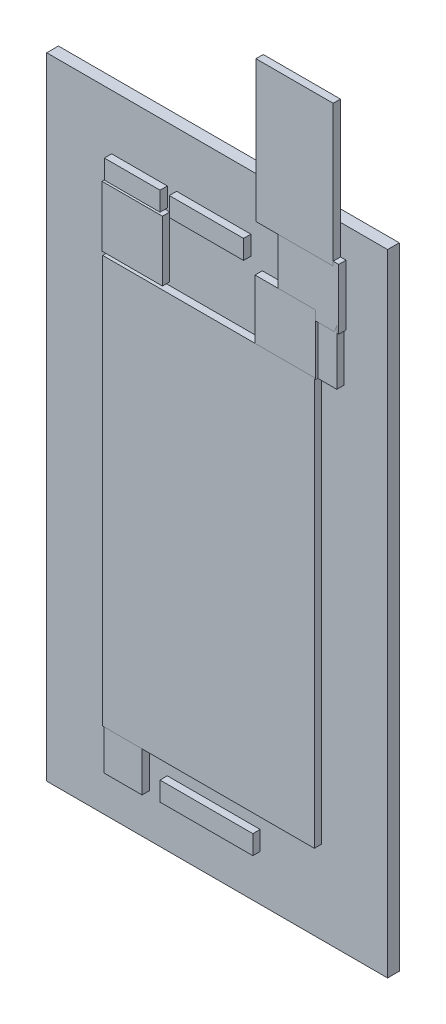
from build123d import *

# Parameters (mm, degrees)
SKETCH1_W                        = 46.66
SKETCH1_H                        = 86.35
BOARD_DEPTH                      = 1.6
SKETCH2_W                        = 8.2804
SKETCH2_H                        = 8.2804
EXTRUDE_E3_5_8_1_DEPTH           = 1
SKETCH3_W                        = 8.2804
SKETCH3_H                        = 8.2804
EXTRUDE_E3_5_8_2_DEPTH           = 1
SKETCH4_W                        = 8.2804
SKETCH4_H                        = 8.2804
EXTRUDE_E3_5_8_3_DEPTH           = 1
SKETCH5_W                        = 10.16
SKETCH5_H                        = 2.6162
DO41_10_1_DEPTH                  = 1
SKETCH6_W                        = 10.5664
SKETCH6_H                        = 19.304
TO220H_1_DEPTH                   = 1
SKETCH7_W                        = 5.2324
SKETCH7_H                        = 5.9182
DIL04_1_DEPTH                    = 1
SKETCH8_W                        = 13.0048
SKETCH8_H                        = 2.286
EXTRUDE_0207_12_1_DEPTH          = 1
SKETCH9_W                        = 13.0048
SKETCH9_H                        = 2.286
EXTRUDE_0207_12_2_DEPTH          = 1
SKETCH10_W                       = 2.6162
SKETCH10_H                       = 7.62
EXTRUDE_1X03_1_DEPTH             = 1
SKETCH11_W                       = 7.62
SKETCH11_H                       = 2.6162
EXTRUDE_1X03_2_DEPTH             = 1
SKETCH12_W                       = 12.7
SKETCH12_H                       = 2.6162
EXTRUDE_1X05_1_DEPTH             = 1
SKETCH13_W                       = 28.97
SKETCH13_H                       = 55.8
MODULE_ESP32_DEVKITC_32U_1_DEPTH = 1


with BuildPart() as part:
    # Sketch1 → BOARD (new body)
    with BuildSketch(Plane.XY):
        with Locations((13.17, 43.175)):
            Rectangle(SKETCH1_W, SKETCH1_H)
    extrude(amount=BOARD_DEPTH)


with BuildPart() as body_2:
    # Sketch2 → Extrude E3_5-8-1 (new body)
    with BuildSketch(Plane.XY.offset(1.6)):
        with Locations((2.54, 71.755)):
            Rectangle(SKETCH2_W, SKETCH2_H)
    extrude(amount=EXTRUDE_E3_5_8_1_DEPTH)


with BuildPart() as body_3:
    # Sketch3 → Extrude E3_5-8-2 (new body)
    with BuildSketch(Plane.XY.offset(1.6)):
        with Locations((26.67, 78.105)):
            Rectangle(SKETCH3_W, SKETCH3_H)
    extrude(amount=EXTRUDE_E3_5_8_2_DEPTH)


with BuildPart() as body_4:
    # Sketch4 → Extrude E3_5-8-3 (new body)
    with BuildSketch(Plane.XY.offset(1.6)):
        with Locations((23.495, 71.12)):
            Rectangle(SKETCH4_W, SKETCH4_H)
    extrude(amount=EXTRUDE_E3_5_8_3_DEPTH)


with BuildPart() as body_5:
    # Sketch5 → DO41-10-1 (new body)
    with BuildSketch(Plane.XY.offset(1.6)):
        with Locations((12.7, 77.5081)):
            Rectangle(SKETCH5_W, SKETCH5_H)
    extrude(amount=DO41_10_1_DEPTH)


with BuildPart() as body_6:
    # Sketch6 → TO220H-1 (new body)
    with BuildSketch(Plane.XY.offset(1.6)):
        with Locations((24.765, 91.313)):
            Rectangle(SKETCH6_W, SKETCH6_H)
    extrude(amount=TO220H_1_DEPTH)


with BuildPart() as body_7:
    # Sketch7 → DIL04-1 (new body)
    with BuildSketch(Plane.XY.offset(1.6)):
        with Locations((1.27, 8.8519)):
            Rectangle(SKETCH7_W, SKETCH7_H)
    extrude(amount=DIL04_1_DEPTH)


with BuildPart() as body_8:
    # Sketch8 → Extrude 0207_12-1 (new body)
    with BuildSketch(Plane.XY.offset(1.6)):
        with Locations((10.0076, 34.29)):
            Rectangle(SKETCH8_W, SKETCH8_H)
    extrude(amount=EXTRUDE_0207_12_1_DEPTH)


with BuildPart() as body_9:
    # Sketch9 → Extrude 0207_12-2 (new body)
    with BuildSketch(Plane.XY.offset(1.6)):
        with Locations((10.0076, 41.91)):
            Rectangle(SKETCH9_W, SKETCH9_H)
    extrude(amount=EXTRUDE_0207_12_2_DEPTH)


with BuildPart() as body_10:
    # Sketch10 → Extrude 1X03-1 (new body)
    with BuildSketch(Plane.XY.offset(1.6)):
        with Locations((29.2481, 71.12)):
            Rectangle(SKETCH10_W, SKETCH10_H)
    extrude(amount=EXTRUDE_1X03_1_DEPTH)


with BuildPart() as body_11:
    # Sketch11 → Extrude 1X03-2 (new body)
    with BuildSketch(Plane.XY.offset(1.6)):
        with Locations((2.54, 77.5081)):
            Rectangle(SKETCH11_W, SKETCH11_H)
    extrude(amount=EXTRUDE_1X03_2_DEPTH)


with BuildPart() as body_12:
    # Sketch12 → Extrude 1X05-1 (new body)
    with BuildSketch(Plane.XY.offset(1.6)):
        with Locations((12.7, 7.5819)):
            Rectangle(SKETCH12_W, SKETCH12_H)
    extrude(amount=EXTRUDE_1X05_1_DEPTH)


with BuildPart() as body_13:
    # Sketch13 → MODULE_ESP32-DEVKITC-32U-1 (new body)
    with BuildSketch(Plane.XY.offset(1.6)):
        with Locations((12.985, 39.26)):
            Rectangle(SKETCH13_W, SKETCH13_H)
    extrude(amount=MODULE_ESP32_DEVKITC_32U_1_DEPTH)


solid = Compound([part.part, body_2.part, body_3.part, body_4.part, body_5.part, body_6.part, body_7.part, body_8.part, body_9.part, body_10.part, body_11.part, body_12.part, body_13.part])
